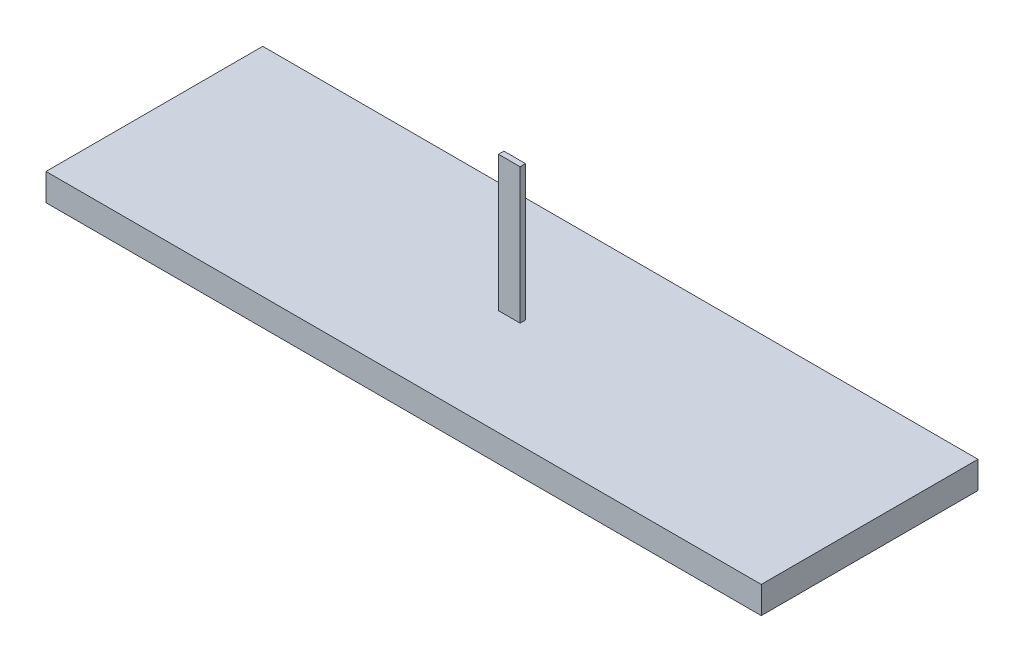
from build123d import *

# Parameters (mm, degrees)
SKETCH1_W                = 132
SKETCH1_H                = 40
BOSS_EXTRUDE1_DEPTH      = 5
SKETCH2_W                = 4
SKETCH2_H                = 30
BOSS_EXTRUDE2_DEPTH      = 0.5
BOSS_EXTRUDE2_DEPTH_BACK = 0.5


with BuildPart() as part:
    # Sketch1 → Boss-Extrude1 (new body)
    with BuildSketch(Plane(origin=(0, 0, 0), x_dir=(1, 0, 0), z_dir=(0, 1, 0))):
        Rectangle(SKETCH1_W, SKETCH1_H)
    extrude(amount=BOSS_EXTRUDE1_DEPTH)

    # Sketch2 → Boss-Extrude2 (add, two sides)
    with BuildSketch(Plane.XY) as boss_extrude2_sk:
        with Locations((0, 15)):
            Rectangle(SKETCH2_W, SKETCH2_H)
    extrude(amount=BOSS_EXTRUDE2_DEPTH)
    extrude(boss_extrude2_sk.sketch, amount=-BOSS_EXTRUDE2_DEPTH_BACK)


solid = part.part
